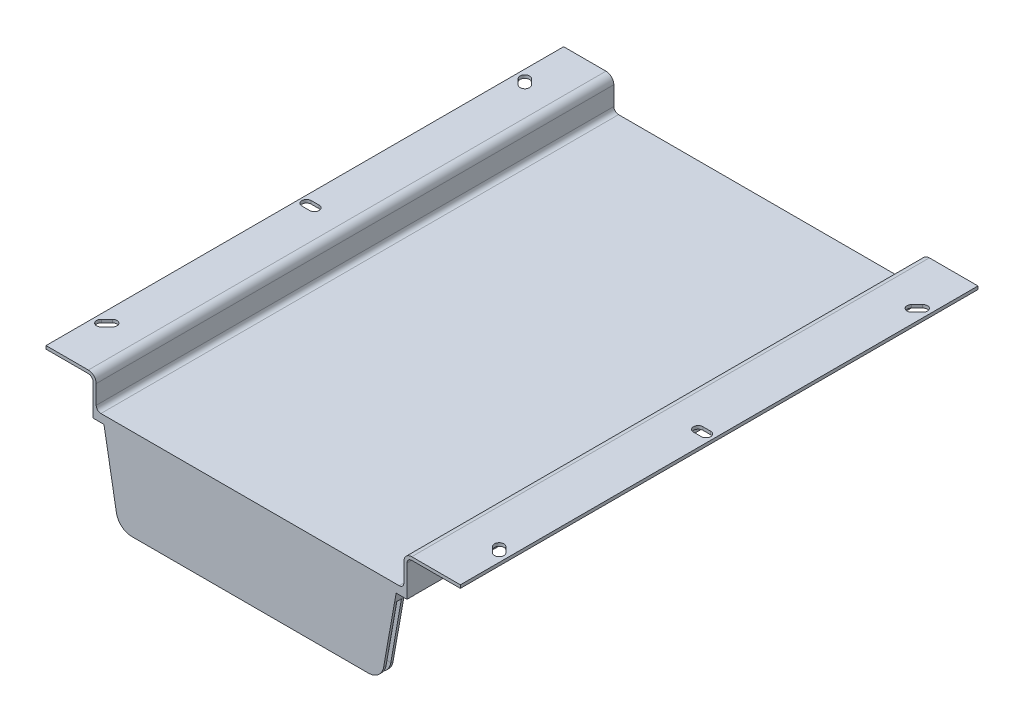
from build123d import *

# Parameters (mm, degrees)
BOSS_EXTRU_1_DEPTH       = 320
BOSS_EXTRU_1_DEPTH_BACK  = 10
ENL_V_MAT_EXTRU_1_DEPTH  = 300
ESQUISSE3_W              = 196.156872589
ESQUISSE3_H              = 6
BOSS_EXTRU_2_DEPTH       = 56.1
ESQUISSE41_W             = 200.156872589
ESQUISSE41_H             = 330
BOSS_EXTRU_9_DEPTH       = 3
ENL_V_MAT_EXTRU_22_DEPTH = 6
CONG_8_R                 = 10
CONG_7_R                 = 0.2
ESQUISSE43_W             = 6.98
ESQUISSE43_H             = 5
BOSS_EXTRU_10_DEPTH      = 0.05
ESQUISSE44_W             = 6
ESQUISSE44_H             = 6
BOSS_EXTRU_11_DEPTH      = 0.05
ESQUISSE45_W             = 6.978514333
ESQUISSE45_H             = 6
BOSS_EXTRU_12_DEPTH      = 0.05
ESQUISSE46_W             = 6
ESQUISSE46_H             = 6
BOSS_EXTRU_13_DEPTH      = 0.05
ENL_V_MAT_EXTRU_23_DEPTH = 3.5
CONG_11_R                = 2.5
ESQUISSE48_W             = 3
ESQUISSE48_H             = 3


with BuildPart() as part:
    # Esquisse1 → Boss.-Extru.1 (new body, two sides)
    with BuildSketch(Plane.XY) as boss_extru_1_sk:
        with BuildLine():
            Line((-107.913003101, 2), (82.243869488, 2))
            ThreePointArc((82.243869488, 2), (84.365189832, 2.878679656), (85.243869488, 5))
            Line((85.243869488, 5), (85.243869488, 17))
            ThreePointArc((85.243869488, 17), (86.708335582, 20.535533906), (90.243869488, 22))
            Line((90.243869488, 22), (116.243869488, 22))
            Line((116.243869488, 22), (121.243869488, 22))
            Line((121.243869488, 22), (121.243869488, 20))
            Line((121.243869488, 20), (116.243869488, 20))
            Line((116.243869488, 20), (90.243869488, 20))
            ThreePointArc((90.243869488, 20), (88.122549145, 19.121320344), (87.243869488, 17))
            Line((87.243869488, 17), (87.243869488, 0))
            Line((87.243869488, 0), (-112.913003101, 0))
            Line((-112.913003101, 0), (-112.913003101, 17))
            ThreePointArc((-112.913003101, 17), (-113.791682758, 19.121320344), (-115.913003101, 20))
            Line((-115.913003101, 20), (-137.913003101, 20))
            Line((-137.913003101, 20), (-142.913003101, 20))
            Line((-142.913003101, 20), (-142.913003101, 22))
            Line((-142.913003101, 22), (-137.913003101, 22))
            Line((-137.913003101, 22), (-115.913003101, 22))
            ThreePointArc((-115.913003101, 22), (-112.377469195, 20.535533906), (-110.913003101, 17))
            Line((-110.913003101, 17), (-110.913003101, 5))
            ThreePointArc((-110.913003101, 5), (-110.034323445, 2.878679656), (-107.913003101, 2))
        make_face()
    extrude(amount=BOSS_EXTRU_1_DEPTH)
    extrude(boss_extru_1_sk.sketch, amount=-BOSS_EXTRU_1_DEPTH_BACK)

    # Esquisse2 → Enlèv. mat.-Extru.1 (cut)
    with BuildSketch(Plane.XZ.offset(-20)):
        with BuildLine():
            Line((-139.784323445, 22.121320344), (-136.284323445, 25.621320344))
            ThreePointArc((-136.284323445, 25.621320344), (-132.041682758, 25.621320344), (-132.041682758, 21.378679656))
            Line((-132.041682758, 21.378679656), (-135.541682758, 17.878679656))
            ThreePointArc((-135.541682758, 17.878679656), (-139.784323445, 17.878679656), (-139.784323445, 22.121320344))
        make_face()
        with BuildLine():
            Line((-136.284323445, 284.378679656), (-139.784323445, 287.878679656))
            ThreePointArc((-139.784323445, 287.878679656), (-139.784323445, 292.121320344), (-135.541682758, 292.121320344))
            Line((-135.541682758, 292.121320344), (-132.041682758, 288.621320344))
            ThreePointArc((-132.041682758, 288.621320344), (-132.041682758, 284.378679656), (-136.284323445, 284.378679656))
        make_face()
        with BuildLine():
            Line((118.115189832, 287.878679656), (114.615189832, 284.378679656))
            ThreePointArc((114.615189832, 284.378679656), (110.372549145, 284.378679656), (110.372549145, 288.621320344))
            Line((110.372549145, 288.621320344), (113.872549145, 292.121320344))
            ThreePointArc((113.872549145, 292.121320344), (118.115189832, 292.121320344), (118.115189832, 287.878679656))
        make_face()
        with BuildLine():
            Line((114.615189832, 25.621320344), (118.115189832, 22.121320344))
            ThreePointArc((118.115189832, 22.121320344), (118.115189832, 17.878679656), (113.872549145, 17.878679656))
            Line((113.872549145, 17.878679656), (110.372549145, 21.378679656))
            ThreePointArc((110.372549145, 21.378679656), (110.372549145, 25.621320344), (114.615189832, 25.621320344))
        make_face()
        with BuildLine():
            Line((116.243869488, 155.403419264), (111.243869488, 155.403419264))
            ThreePointArc((111.243869488, 155.403419264), (108.243869488, 158.403419264), (111.243869488, 161.403419264))
            Line((111.243869488, 161.403419264), (116.243869488, 161.403419264))
            ThreePointArc((116.243869488, 161.403419264), (119.243869488, 158.403419264), (116.243869488, 155.403419264))
        make_face()
        with BuildLine():
            Line((-138.413003101, 161.403419264), (-133.413003101, 161.403419264))
            ThreePointArc((-133.413003101, 161.403419264), (-130.413003101, 158.403419264), (-133.413003101, 155.403419264))
            Line((-133.413003101, 155.403419264), (-138.413003101, 155.403419264))
            ThreePointArc((-138.413003101, 155.403419264), (-141.413003101, 158.403419264), (-138.413003101, 161.403419264))
        make_face()
    extrude(amount=-ENL_V_MAT_EXTRU_1_DEPTH, mode=Mode.SUBTRACT)

    # Esquisse3 → Boss.-Extru.2 (add)
    with BuildSketch(Plane(origin=(0, 0, 0), x_dir=(-1, 0, 0), z_dir=(0, -1, 0))):
        with Locations((12.834566806, -317)):
            Rectangle(ESQUISSE3_W, ESQUISSE3_H)
    extrude(amount=BOSS_EXTRU_2_DEPTH)

    # Esquisse41 → Boss.-Extru.9 (add)
    with BuildSketch(Plane.XZ):
        with Locations((-12.834566806, 155)):
            Rectangle(ESQUISSE41_W, ESQUISSE41_H)
        with BuildLine():
            Line((81.243869488, 314), (-106.913003101, 314))
            Line((-106.913003101, 314), (-106.913003101, 6))
            ThreePointArc((-106.913003101, 6), (-103.984070913, -1.071067812), (-96.913003101, -4))
            Line((-96.913003101, -4), (71.243869488, -4))
            ThreePointArc((71.243869488, -4), (78.3149373, -1.071067812), (81.243869488, 6))
            Line((81.243869488, 6), (81.243869488, 314))
        make_face(mode=Mode.SUBTRACT)
    extrude(amount=BOSS_EXTRU_9_DEPTH)

    # Esquisse24 → Enlèv. mat.-Extru.22 (cut)
    with BuildSketch(Plane.XY.offset(320)):
        Polygon((80.263869488, -3), (69.213869488, -65.686319951), (85.243869488, -65.686319951), (85.243869488, -3), align=None)
        Polygon((-105.934488768, -3), (-94.881199239, -65.686319951), (-110.913003101, -65.686319951), (-110.913003101, -3), align=None)
    extrude(amount=-ENL_V_MAT_EXTRU_22_DEPTH, mode=Mode.SUBTRACT)

    # Congé8
    cong_8_edges = [part.edges().sort_by_distance(p)[0] for p in [
        (-96.571526093, -56.1, 317),
        (70.903693289, -56.1, 317),
    ]]
    fillet(cong_8_edges, radius=CONG_8_R)

    # Congé7
    cong_7_edges = [part.edges().sort_by_distance(p)[0] for p in [
        (-142.913003101, 21, -10),
    ]]
    fillet(cong_7_edges, radius=CONG_7_R)

    # Esquisse43 → Boss.-Extru.10 (add)
    with BuildSketch(Plane.XZ.offset(3)):
        with Locations((83.753869488, 317.5)):
            Rectangle(ESQUISSE43_W, ESQUISSE43_H)
    extrude(amount=BOSS_EXTRU_10_DEPTH)

    # Esquisse44 → Boss.-Extru.11 (add)
    with BuildSketch(Plane(origin=(78.357901362, -13.812500251, 0), x_dir=(0, 0, -1), z_dir=(0.984816589, -0.173598057, 0))):
        with Locations((-317, 7.973810121)):
            Rectangle(ESQUISSE44_W, ESQUISSE44_H)
    extrude(amount=BOSS_EXTRU_11_DEPTH)

    # Esquisse45 → Boss.-Extru.12 (add)
    with BuildSketch(Plane.XZ.offset(3)):
        with Locations((-109.423745935, 317)):
            Rectangle(ESQUISSE45_W, ESQUISSE45_H)
    extrude(amount=BOSS_EXTRU_12_DEPTH)

    # Esquisse46 → Boss.-Extru.13 (add)
    with BuildSketch(Plane(origin=(-103.25320329, -18.206325585, 0), x_dir=(0, 0, 1), z_dir=(-0.984807753, -0.173648178, 0))):
        with Locations((317, 12.440907668)):
            Rectangle(ESQUISSE46_W, ESQUISSE46_H)
    extrude(amount=BOSS_EXTRU_13_DEPTH)

    # Enlèvement de matière-Balayage1: sweep along a path in Esquisse47
    with BuildLine(Plane.XZ.offset(3)) as enl_vement_de_mati_re_balayage1_path:
        Line((84.243869488, 298.46050791), (84.243869488, 5))
        ThreePointArc((84.243869488, 5), (80.729150862, -3.485281374), (72.243869488, -7))
        Line((72.243869488, -7), (-97.913003101, -7))
        ThreePointArc((-97.913003101, -7), (-106.398284476, -3.485281374), (-109.913003101, 5))
        Line((-109.913003101, 5), (-109.913003101, 298.46050791))
    # Esquisse3D1 → Enlèvement de matière-Balayage1 (sweep, cut)
    with BuildSketch(Plane(origin=(-48.798071116, -0.937456497, -5.5), x_dir=(0, -0.624695048, -0.780868809), z_dir=(1, 0, 0))):
        Polygon((0, 0), (1.499268114, -1.874085143), (3.841874542, 0), (2.342606428, 1.874085143), align=None)
    sweep(path=enl_vement_de_mati_re_balayage1_path.line, mode=Mode.SUBTRACT)

    # Esquisse50 → Enlèv. mat.-Extru.23 (cut)
    with BuildSketch(Plane(origin=(0, 0, 314), x_dir=(-1, 0, 0), z_dir=(0, 0, -1))):
        with BuildLine():
            Line((87.39220148, -52.1), (-61.673120332, -52.1))
            ThreePointArc((-61.673120332, -52.1), (-66.172770053, -50.462196601), (-68.566836458, -46.315186396))
            Line((-68.566836458, -46.315186396), (-76.731022999, 0))
            Line((-76.731022999, 0), (102.452534593, 0))
            Line((102.452534593, 0), (94.285855751, -46.315537244))
            ThreePointArc((94.285855751, -46.315537244), (91.891714748, -50.462311102), (87.39220148, -52.1))
        make_face()
    extrude(amount=-ENL_V_MAT_EXTRU_23_DEPTH, mode=Mode.SUBTRACT)

    # Congé11
    cong_11_edges = [part.edges().sort_by_distance(p)[0] for p in [
        (-98.369195172, -23.157768622, 317.5),
        (-91.891714748, -50.462311102, 317.5),
        (-12.859540574, -52.1, 317.5),
        (66.172770053, -50.462196601, 317.5),
        (72.648929728, -23.157593198, 317.5),
    ]]
    fillet(cong_11_edges, radius=CONG_11_R)

    # Enlèvement de matière-Balayage2: sweep along a curve in space
    with BuildLine() as enl_vement_de_mati_re_balayage2_path:
        Line((79.221345133, -8.914209531, 317), (72.358298385, -47.836481777, 317))
        ThreePointArc((72.358298385, -47.836481777, 317), (68.938096952, -53.760444431, 317), (62.510220855, -56.1, 317))
        Line((-8.284645145, -56.1, 317), (62.510220855, -56.1, 317))
        Line((-8.284645145, -56.1, 317), (-88.180529781, -56.1, 317))
        ThreePointArc((-98.028607311, -47.836481777, 317), (-94.608405878, -53.760444431, 317), (-88.180529781, -56.1, 317))
        Line((-104.892599702, -8.908846518, 317), (-98.028607311, -47.836481777, 317))
    # Esquisse48 → Enlèvement de matière-Balayage2 (sweep, cut)
    with BuildSketch(Plane(origin=(0, 0, 0), x_dir=(0, 0, -1), z_dir=(1, 0, 0))):
        with Locations((-317, -55.2)):
            Rectangle(ESQUISSE48_W, ESQUISSE48_H)
    sweep(path=enl_vement_de_mati_re_balayage2_path.line, mode=Mode.SUBTRACT)


solid = part.part
